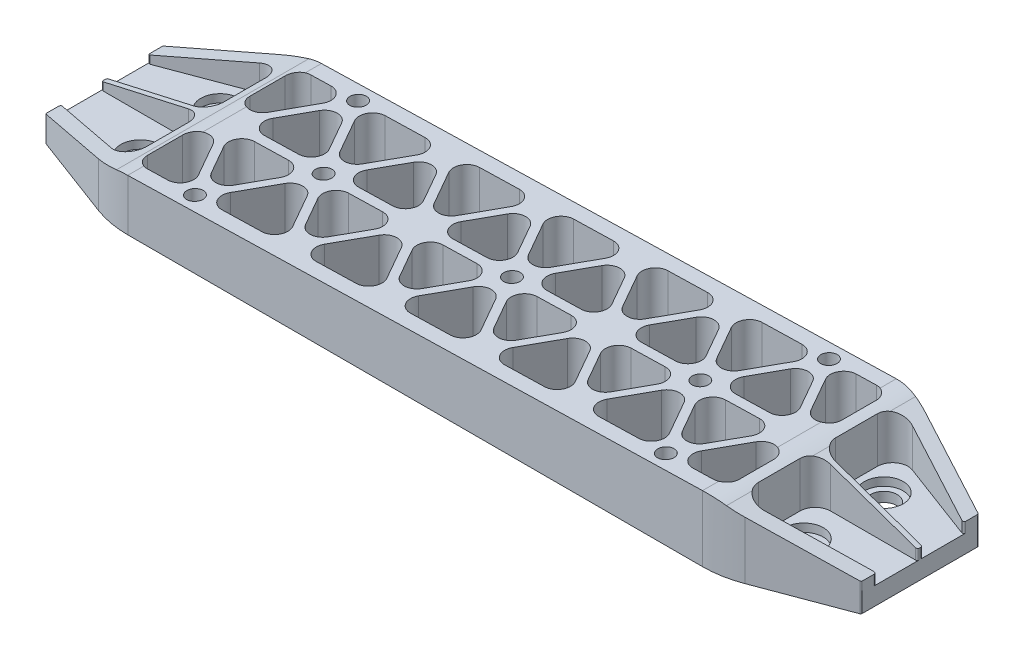
from build123d import *

# Parameters (mm, degrees)
BOSS_EXTRUDE1_DEPTH = 17.1704
SKETCH2_R           = 3.4925
BOSS_EXTRUDE2_DEPTH = 5.08
FILLET1_R           = 25.4
FILLET2_R           = 0.381
CUT_EXTRUDE1_START  = -22.2504
SKETCH3_R           = 2.0193
CUT_EXTRUDE1_DEPTH  = 22.2504
CUT_EXTRUDE2_DEPTH  = 12.7
CUT_EXTRUDE3_REACH  = 11.55
SKETCH6_R           = 3.302
SKETCH7_R           = 4.826
CUT_EXTRUDE4_DEPTH  = 2.032
FILLET3_R           = 0.381
CUT_EXTRUDE5_DEPTH  = 48.26


with BuildPart() as part:
    # Sketch1 → Boss-Extrude1 (new body)
    with BuildSketch(Plane(origin=(0, 0, 0), x_dir=(1, 0, 0), z_dir=(0, 1, 0))):
        Polygon((25.4, 0), (177.8, 0), (203.2, -9.525), (203.2, -38.735), (177.8, -48.26), (25.4, -48.26), (0, -38.735), (0, -9.525), align=None)
    extrude(amount=-BOSS_EXTRUDE1_DEPTH)

    # Sketch2 → Boss-Extrude2 (add)
    with BuildSketch(Plane.XZ.offset(17.1704)):
        with Locations((54.6608, 24.13)):
            Circle(SKETCH2_R)
        with Locations((101.6, 24.13)):
            Circle(SKETCH2_R)
        with Locations((148.5392, 24.13)):
            Circle(SKETCH2_R)
    extrude(amount=BOSS_EXTRUDE2_DEPTH)

    # Fillet1
    fillet1_edges = [part.edges().sort_by_distance(p)[0] for p in [
        (25.4, -8.5852, 0),
        (177.8, -8.5852, 0),
        (177.8, -8.5852, 48.26),
        (25.4, -8.5852, 48.26),
    ]]
    fillet(fillet1_edges, radius=FILLET1_R)

    # Fillet2
    fillet2_edges = [part.edges().sort_by_distance(p)[0] for p in [
        (203.2, -8.5852, 9.525),
        (203.2, -8.5852, 38.735),
        (0, -8.5852, 38.735),
        (0, -8.5852, 9.525),
    ]]
    fillet(fillet2_edges, radius=FILLET2_R)

    # Sketch3 → Cut-Extrude1 (cut)
    with BuildSketch(Plane(origin=(0, 0, 0), x_dir=(1, 0, 0), z_dir=(0, 1, 0)).offset(CUT_EXTRUDE1_START)):
        with Locations((42.92904253, -3.81)):
            Circle(SKETCH3_R)
        with Locations((42.92904253, -44.45)):
            Circle(SKETCH3_R)
        with Locations((54.6608, -24.13)):
            Circle(SKETCH3_R)
        with Locations((101.58782988, -24.13)):
            Circle(SKETCH3_R)
        with Locations((148.514859759, -24.13)):
            Circle(SKETCH3_R)
        with Locations((160.246617229, -3.81)):
            Circle(SKETCH3_R)
        with Locations((160.246617229, -44.45)):
            Circle(SKETCH3_R)
        with BuildLine():
            Line((57.454424748, -31.0007), (62.425756975, -39.6113))
            ThreePointArc((62.425756975, -39.6113), (62.425756975, -42.8371), (59.632132228, -44.45))
            Line((59.632132228, -44.45), (49.689467772, -44.45))
            ThreePointArc((49.689467772, -44.45), (46.895843025, -42.8371), (46.895843025, -39.6113))
            Line((46.895843025, -39.6113), (51.867175252, -31.0007))
            ThreePointArc((51.867175252, -31.0007), (54.6608, -29.3878), (57.454424748, -31.0007))
        make_face()
        with BuildLine():
            Line((38.690945144, -25.4), (47.167139916, -25.4))
            ThreePointArc((47.167139916, -25.4), (49.960764664, -27.0129), (49.960764664, -30.2387))
            Line((49.960764664, -30.2387), (45.722667278, -37.5793))
            ThreePointArc((45.722667278, -37.5793), (42.92904253, -39.1922), (40.135417783, -37.5793))
            Line((40.135417783, -37.5793), (35.897320397, -30.2387))
            ThreePointArc((35.897320397, -30.2387), (35.897320397, -27.0129), (38.690945144, -25.4))
        make_face()
        with BuildLine():
            Line((40.135417783, -10.6807), (35.897320397, -18.0213))
            ThreePointArc((35.897320397, -18.0213), (35.897320397, -21.2471), (38.690945144, -22.86))
            Line((38.690945144, -22.86), (47.167139916, -22.86))
            ThreePointArc((47.167139916, -22.86), (49.960764664, -21.2471), (49.960764664, -18.0213))
            Line((49.960764664, -18.0213), (45.722667278, -10.6807))
            ThreePointArc((45.722667278, -10.6807), (42.92904253, -9.0678), (40.135417783, -10.6807))
        make_face()
        with BuildLine():
            Line((46.895843025, -8.6487), (51.867175252, -17.2593))
            ThreePointArc((51.867175252, -17.2593), (54.6608, -18.8722), (57.454424748, -17.2593))
            Line((57.454424748, -17.2593), (62.425756975, -8.6487))
            ThreePointArc((62.425756975, -8.6487), (62.425756975, -5.4229), (59.632132228, -3.81))
            Line((59.632132228, -3.81), (49.689467772, -3.81))
            ThreePointArc((49.689467772, -3.81), (46.895843025, -5.4229), (46.895843025, -8.6487))
        make_face()
        with BuildLine():
            Line((63.605017783, -37.5793), (59.366920397, -30.2387))
            ThreePointArc((59.366920397, -30.2387), (59.366920397, -27.0129), (62.160545144, -25.4))
            Line((62.160545144, -25.4), (70.636739916, -25.4))
            ThreePointArc((70.636739916, -25.4), (73.430364664, -27.0129), (73.430364664, -30.2387))
            Line((73.430364664, -30.2387), (69.192267278, -37.5793))
            ThreePointArc((69.192267278, -37.5793), (66.39864253, -39.1922), (63.605017783, -37.5793))
        make_face()
        with BuildLine():
            Line((70.365443025, -39.6113), (75.336775252, -31.0007))
            ThreePointArc((75.336775252, -31.0007), (78.1304, -29.3878), (80.924024748, -31.0007))
            Line((80.924024748, -31.0007), (85.895356975, -39.6113))
            ThreePointArc((85.895356975, -39.6113), (85.895356975, -42.8371), (83.101732228, -44.45))
            Line((83.101732228, -44.45), (73.159067772, -44.45))
            ThreePointArc((73.159067772, -44.45), (70.365443025, -42.8371), (70.365443025, -39.6113))
        make_face()
        with BuildLine():
            Line((70.365443025, -8.6487), (75.336775252, -17.2593))
            ThreePointArc((75.336775252, -17.2593), (78.1304, -18.8722), (80.924024748, -17.2593))
            Line((80.924024748, -17.2593), (85.895356975, -8.6487))
            ThreePointArc((85.895356975, -8.6487), (85.895356975, -5.4229), (83.101732228, -3.81))
            Line((83.101732228, -3.81), (73.159067772, -3.81))
            ThreePointArc((73.159067772, -3.81), (70.365443025, -5.4229), (70.365443025, -8.6487))
        make_face()
        with BuildLine():
            Line((63.605017783, -10.6807), (59.366920397, -18.0213))
            ThreePointArc((59.366920397, -18.0213), (59.366920397, -21.2471), (62.160545144, -22.86))
            Line((62.160545144, -22.86), (70.636739916, -22.86))
            ThreePointArc((70.636739916, -22.86), (73.430364664, -21.2471), (73.430364664, -18.0213))
            Line((73.430364664, -18.0213), (69.192267278, -10.6807))
            ThreePointArc((69.192267278, -10.6807), (66.39864253, -9.0678), (63.605017783, -10.6807))
        make_face()
        with BuildLine():
            Line((87.074617783, -37.5793), (82.836520397, -30.2387))
            ThreePointArc((82.836520397, -30.2387), (82.836520397, -27.0129), (85.630145144, -25.4))
            Line((85.630145144, -25.4), (94.106339916, -25.4))
            ThreePointArc((94.106339916, -25.4), (96.899964664, -27.0129), (96.899964664, -30.2387))
            Line((96.899964664, -30.2387), (92.661867278, -37.5793))
            ThreePointArc((92.661867278, -37.5793), (89.86824253, -39.1922), (87.074617783, -37.5793))
        make_face()
        with BuildLine():
            Line((93.835043025, -39.6113), (98.806375252, -31.0007))
            ThreePointArc((98.806375252, -31.0007), (101.6, -29.3878), (104.393624748, -31.0007))
            Line((104.393624748, -31.0007), (109.364956975, -39.6113))
            ThreePointArc((109.364956975, -39.6113), (109.364956975, -42.8371), (106.571332228, -44.45))
            Line((106.571332228, -44.45), (96.628667772, -44.45))
            ThreePointArc((96.628667772, -44.45), (93.835043025, -42.8371), (93.835043025, -39.6113))
        make_face()
        with BuildLine():
            Line((93.835043025, -8.6487), (98.806375252, -17.2593))
            ThreePointArc((98.806375252, -17.2593), (101.6, -18.8722), (104.393624748, -17.2593))
            Line((104.393624748, -17.2593), (109.364956975, -8.6487))
            ThreePointArc((109.364956975, -8.6487), (109.364956975, -5.4229), (106.571332228, -3.81))
            Line((106.571332228, -3.81), (96.628667772, -3.81))
            ThreePointArc((96.628667772, -3.81), (93.835043025, -5.4229), (93.835043025, -8.6487))
        make_face()
        with BuildLine():
            Line((87.074617783, -10.6807), (82.836520397, -18.0213))
            ThreePointArc((82.836520397, -18.0213), (82.836520397, -21.2471), (85.630145144, -22.86))
            Line((85.630145144, -22.86), (94.106339916, -22.86))
            ThreePointArc((94.106339916, -22.86), (96.899964664, -21.2471), (96.899964664, -18.0213))
            Line((96.899964664, -18.0213), (92.661867278, -10.6807))
            ThreePointArc((92.661867278, -10.6807), (89.86824253, -9.0678), (87.074617783, -10.6807))
        make_face()
        with BuildLine():
            Line((110.544217783, -37.5793), (106.306120397, -30.2387))
            ThreePointArc((106.306120397, -30.2387), (106.306120397, -27.0129), (109.099745144, -25.4))
            Line((109.099745144, -25.4), (117.575939916, -25.4))
            ThreePointArc((117.575939916, -25.4), (120.369564664, -27.0129), (120.369564664, -30.2387))
            Line((120.369564664, -30.2387), (116.131467278, -37.5793))
            ThreePointArc((116.131467278, -37.5793), (113.33784253, -39.1922), (110.544217783, -37.5793))
        make_face()
        with BuildLine():
            Line((117.304643025, -39.6113), (122.275975252, -31.0007))
            ThreePointArc((122.275975252, -31.0007), (125.0696, -29.3878), (127.863224748, -31.0007))
            Line((127.863224748, -31.0007), (132.834556975, -39.6113))
            ThreePointArc((132.834556975, -39.6113), (132.834556975, -42.8371), (130.040932228, -44.45))
            Line((130.040932228, -44.45), (120.098267772, -44.45))
            ThreePointArc((120.098267772, -44.45), (117.304643025, -42.8371), (117.304643025, -39.6113))
        make_face()
        with BuildLine():
            Line((117.304643025, -8.6487), (122.275975252, -17.2593))
            ThreePointArc((122.275975252, -17.2593), (125.0696, -18.8722), (127.863224748, -17.2593))
            Line((127.863224748, -17.2593), (132.834556975, -8.6487))
            ThreePointArc((132.834556975, -8.6487), (132.834556975, -5.4229), (130.040932228, -3.81))
            Line((130.040932228, -3.81), (120.098267772, -3.81))
            ThreePointArc((120.098267772, -3.81), (117.304643025, -5.4229), (117.304643025, -8.6487))
        make_face()
        with BuildLine():
            Line((110.544217783, -10.6807), (106.306120397, -18.0213))
            ThreePointArc((106.306120397, -18.0213), (106.306120397, -21.2471), (109.099745144, -22.86))
            Line((109.099745144, -22.86), (117.575939916, -22.86))
            ThreePointArc((117.575939916, -22.86), (120.369564664, -21.2471), (120.369564664, -18.0213))
            Line((120.369564664, -18.0213), (116.131467278, -10.6807))
            ThreePointArc((116.131467278, -10.6807), (113.33784253, -9.0678), (110.544217783, -10.6807))
        make_face()
        with BuildLine():
            Line((134.013817783, -37.5793), (129.775720397, -30.2387))
            ThreePointArc((129.775720397, -30.2387), (129.775720397, -27.0129), (132.569345144, -25.4))
            Line((132.569345144, -25.4), (141.045539916, -25.4))
            ThreePointArc((141.045539916, -25.4), (143.839164664, -27.0129), (143.839164664, -30.2387))
            Line((143.839164664, -30.2387), (139.601067278, -37.5793))
            ThreePointArc((139.601067278, -37.5793), (136.80744253, -39.1922), (134.013817783, -37.5793))
        make_face()
        with BuildLine():
            Line((140.774243025, -39.6113), (145.745575252, -31.0007))
            ThreePointArc((145.745575252, -31.0007), (148.5392, -29.3878), (151.332824748, -31.0007))
            Line((151.332824748, -31.0007), (156.304156975, -39.6113))
            ThreePointArc((156.304156975, -39.6113), (156.304156975, -42.8371), (153.510532228, -44.45))
            Line((153.510532228, -44.45), (143.567867772, -44.45))
            ThreePointArc((143.567867772, -44.45), (140.774243025, -42.8371), (140.774243025, -39.6113))
        make_face()
        with BuildLine():
            Line((140.774243025, -8.6487), (145.745575252, -17.2593))
            ThreePointArc((145.745575252, -17.2593), (148.5392, -18.8722), (151.332824748, -17.2593))
            Line((151.332824748, -17.2593), (156.304156975, -8.6487))
            ThreePointArc((156.304156975, -8.6487), (156.304156975, -5.4229), (153.510532228, -3.81))
            Line((153.510532228, -3.81), (143.567867772, -3.81))
            ThreePointArc((143.567867772, -3.81), (140.774243025, -5.4229), (140.774243025, -8.6487))
        make_face()
        with BuildLine():
            Line((134.013817783, -10.6807), (129.775720397, -18.0213))
            ThreePointArc((129.775720397, -18.0213), (129.775720397, -21.2471), (132.569345144, -22.86))
            Line((132.569345144, -22.86), (141.045539916, -22.86))
            ThreePointArc((141.045539916, -22.86), (143.839164664, -21.2471), (143.839164664, -18.0213))
            Line((143.839164664, -18.0213), (139.601067278, -10.6807))
            ThreePointArc((139.601067278, -10.6807), (136.80744253, -9.0678), (134.013817783, -10.6807))
        make_face()
        with BuildLine():
            Line((157.483417783, -37.5793), (153.245320397, -30.2387))
            ThreePointArc((153.245320397, -30.2387), (153.245320397, -27.0129), (156.038945144, -25.4))
            Line((156.038945144, -25.4), (164.515139916, -25.4))
            ThreePointArc((164.515139916, -25.4), (167.308764664, -27.0129), (167.308764664, -30.2387))
            Line((167.308764664, -30.2387), (163.070667278, -37.5793))
            ThreePointArc((163.070667278, -37.5793), (160.27704253, -39.1922), (157.483417783, -37.5793))
        make_face()
        with BuildLine():
            Line((164.243843025, -39.6113), (169.240575252, -30.956705909))
            ThreePointArc((169.240575252, -30.956705909), (172.869098476, -29.453722379), (175.26, -32.569605909))
            Line((175.26, -32.569605909), (175.26, -41.2242))
            ThreePointArc((175.26, -41.2242), (174.315185055, -43.505185055), (172.0342, -44.45))
            Line((172.0342, -44.45), (167.037467772, -44.45))
            ThreePointArc((167.037467772, -44.45), (164.243843025, -42.8371), (164.243843025, -39.6113))
        make_face()
        with BuildLine():
            Line((164.243843025, -8.6487), (169.240575252, -17.303294091))
            ThreePointArc((169.240575252, -17.303294091), (172.869098476, -18.806277621), (175.26, -15.690394091))
            Line((175.26, -15.690394091), (175.26, -7.0358))
            ThreePointArc((175.26, -7.0358), (174.315185055, -4.754814945), (172.0342, -3.81))
            Line((172.0342, -3.81), (167.037467772, -3.81))
            ThreePointArc((167.037467772, -3.81), (164.243843025, -5.4229), (164.243843025, -8.6487))
        make_face()
        with BuildLine():
            Line((157.483417783, -10.6807), (153.245320397, -18.0213))
            ThreePointArc((153.245320397, -18.0213), (153.245320397, -21.2471), (156.038945144, -22.86))
            Line((156.038945144, -22.86), (164.515139916, -22.86))
            ThreePointArc((164.515139916, -22.86), (167.308764664, -21.2471), (167.308764664, -18.0213))
            Line((167.308764664, -18.0213), (163.070667278, -10.6807))
            ThreePointArc((163.070667278, -10.6807), (160.27704253, -9.0678), (157.483417783, -10.6807))
        make_face()
        with BuildLine():
            Line((33.959424748, -30.956705909), (38.956156975, -39.6113))
            ThreePointArc((38.956156975, -39.6113), (38.956156975, -42.8371), (36.162532228, -44.45))
            Line((36.162532228, -44.45), (31.1658, -44.45))
            ThreePointArc((31.1658, -44.45), (28.884814945, -43.505185055), (27.94, -41.2242))
            Line((27.94, -41.2242), (27.94, -32.569605909))
            ThreePointArc((27.94, -32.569605909), (30.330901524, -29.453722379), (33.959424748, -30.956705909))
        make_face()
        with BuildLine():
            Line((33.959424748, -17.303294091), (38.956156975, -8.6487))
            ThreePointArc((38.956156975, -8.6487), (38.956156975, -5.4229), (36.162532228, -3.81))
            Line((36.162532228, -3.81), (31.1658, -3.81))
            ThreePointArc((31.1658, -3.81), (28.884814945, -4.754814945), (27.94, -7.0358))
            Line((27.94, -7.0358), (27.94, -15.690394091))
            ThreePointArc((27.94, -15.690394091), (30.330901524, -18.806277621), (33.959424748, -17.303294091))
        make_face()
    extrude(amount=CUT_EXTRUDE1_DEPTH, mode=Mode.SUBTRACT)

    # Sketch4 → Cut-Extrude2 (cut)
    with BuildSketch(Plane(origin=(0, 0, 0), x_dir=(1, 0, 0), z_dir=(0, 1, 0))):
        with BuildLine():
            Line((0, -13.322809665), (20.252219688, -5.728227282))
            ThreePointArc((20.252219688, -5.728227282), (23.760156332, -6.164104846), (25.4, -9.295641449))
            Line((25.4, -9.295641449), (25.4, -19.685))
            ThreePointArc((25.4, -19.685), (24.284076836, -22.379076836), (21.59, -23.495))
            Line((21.59, -23.495), (0, -23.495))
            Line((0, -23.495), (0, -13.322809665))
        make_face()
        with BuildLine():
            Line((203.2, -13.322809665), (182.947780312, -5.728227282))
            ThreePointArc((182.947780312, -5.728227282), (179.439843668, -6.164104846), (177.8, -9.295641449))
            Line((177.8, -9.295641449), (177.8, -19.685))
            ThreePointArc((177.8, -19.685), (178.915923164, -22.379076836), (181.61, -23.495))
            Line((181.61, -23.495), (203.2, -23.495))
            Line((203.2, -23.495), (203.2, -13.322809665))
        make_face()
        with BuildLine():
            Line((181.61, -24.765), (203.2, -24.765))
            Line((203.2, -24.765), (203.2, -34.937190335))
            Line((203.2, -34.937190335), (182.947780312, -42.531772718))
            ThreePointArc((182.947780312, -42.531772718), (179.439843668, -42.095895154), (177.8, -38.964358551))
            Line((177.8, -38.964358551), (177.8, -28.575))
            ThreePointArc((177.8, -28.575), (178.915923164, -25.880923164), (181.61, -24.765))
        make_face()
        with BuildLine():
            Line((21.59, -24.765), (0, -24.765))
            Line((0, -24.765), (0, -34.937190335))
            Line((0, -34.937190335), (20.252219688, -42.531772718))
            ThreePointArc((20.252219688, -42.531772718), (23.760156332, -42.095895154), (25.4, -38.964358551))
            Line((25.4, -38.964358551), (25.4, -28.575))
            ThreePointArc((25.4, -28.575), (24.284076836, -25.880923164), (21.59, -24.765))
        make_face()
    extrude(amount=-CUT_EXTRUDE2_DEPTH, mode=Mode.SUBTRACT)

    # Sketch6 → Cut-Extrude3 (cut, up to next)
    with BuildSketch(Plane(origin=(0, -12.7, 0), x_dir=(1, 0, 0), z_dir=(0, 1, 0)), mode=Mode.PRIVATE) as cut_extrude3_sk1:
        with Locations((18.923, -14.1732)):
            Circle(SKETCH6_R)
    cut_extrude3_tool1 = extrude(cut_extrude3_sk1.sketch, amount=-CUT_EXTRUDE3_REACH, mode=Mode.PRIVATE) & part.part
    add(cut_extrude3_tool1.solids().sort_by_distance((18.923, -12.7, 14.1732))[0], mode=Mode.SUBTRACT)
    # Sketch6 → Cut-Extrude3 (cut, up to next)
    with BuildSketch(Plane(origin=(0, -12.7, 0), x_dir=(1, 0, 0), z_dir=(0, 1, 0)), mode=Mode.PRIVATE) as cut_extrude3_sk2:
        with Locations((184.277, -14.1732)):
            Circle(SKETCH6_R)
    cut_extrude3_tool2 = extrude(cut_extrude3_sk2.sketch, amount=-CUT_EXTRUDE3_REACH, mode=Mode.PRIVATE) & part.part
    add(cut_extrude3_tool2.solids().sort_by_distance((184.277, -12.7, 14.1732))[0], mode=Mode.SUBTRACT)
    # Sketch6 → Cut-Extrude3 (cut, up to next)
    with BuildSketch(Plane(origin=(0, -12.7, 0), x_dir=(1, 0, 0), z_dir=(0, 1, 0)), mode=Mode.PRIVATE) as cut_extrude3_sk3:
        with Locations((184.277, -34.0868)):
            Circle(SKETCH6_R)
    cut_extrude3_tool3 = extrude(cut_extrude3_sk3.sketch, amount=-CUT_EXTRUDE3_REACH, mode=Mode.PRIVATE) & part.part
    add(cut_extrude3_tool3.solids().sort_by_distance((184.277, -12.7, 34.0868))[0], mode=Mode.SUBTRACT)
    # Sketch6 → Cut-Extrude3 (cut, up to next)
    with BuildSketch(Plane(origin=(0, -12.7, 0), x_dir=(1, 0, 0), z_dir=(0, 1, 0)), mode=Mode.PRIVATE) as cut_extrude3_sk4:
        with Locations((18.923, -34.0868)):
            Circle(SKETCH6_R)
    cut_extrude3_tool4 = extrude(cut_extrude3_sk4.sketch, amount=-CUT_EXTRUDE3_REACH, mode=Mode.PRIVATE) & part.part
    add(cut_extrude3_tool4.solids().sort_by_distance((18.923, -12.7, 34.0868))[0], mode=Mode.SUBTRACT)

    # Sketch7 → Cut-Extrude4 (cut)
    with BuildSketch(Plane(origin=(0, -12.7, 0), x_dir=(1, 0, 0), z_dir=(0, 1, 0))):
        with Locations((18.923, -14.1732)):
            Circle(SKETCH7_R)
        with Locations((18.923, -34.0868)):
            Circle(SKETCH7_R)
        with Locations((184.277, -34.0868)):
            Circle(SKETCH7_R)
        with Locations((184.277, -14.1732)):
            Circle(SKETCH7_R)
    extrude(amount=-CUT_EXTRUDE4_DEPTH, mode=Mode.SUBTRACT)

    # Fillet3
    fillet3_edges = [part.edges().sort_by_distance(p)[0] for p in [
        (0, -6.35, 34.937190335),
        (0, -6.35, 24.765),
        (203.2, -6.35, 24.765),
        (203.2, -6.35, 34.937190335),
        (203.2, -6.35, 13.322809665),
        (203.2, -6.35, 23.495),
        (0, -6.35, 23.495),
        (0, -6.35, 13.322809665),
    ]]
    fillet(fillet3_edges, radius=FILLET3_R)

    # Sketch8 → Cut-Extrude5 (cut)
    with BuildSketch(Plane.XY.offset(48.26)):
        with BuildLine():
            Line((0, 0), (203.2, 0))
            Line((203.2, 0), (203.2, -10.16))
            Line((203.2, -10.16), (178.59483271, -1.592678285))
            ThreePointArc((178.59483271, -1.592678285), (175.936748688, -0.927959479), (173.2026, -0.749935))
            Line((173.2026, -0.749935), (29.9974, -4.330065))
            ThreePointArc((29.9974, -4.330065), (28.501996487, -4.44124587), (27.024758148, -4.698849722))
            Line((27.024758148, -4.698849722), (0, -10.795))
            Line((0, -10.795), (0, 0))
        make_face()
    extrude(amount=-CUT_EXTRUDE5_DEPTH, mode=Mode.SUBTRACT)


solid = part.part
